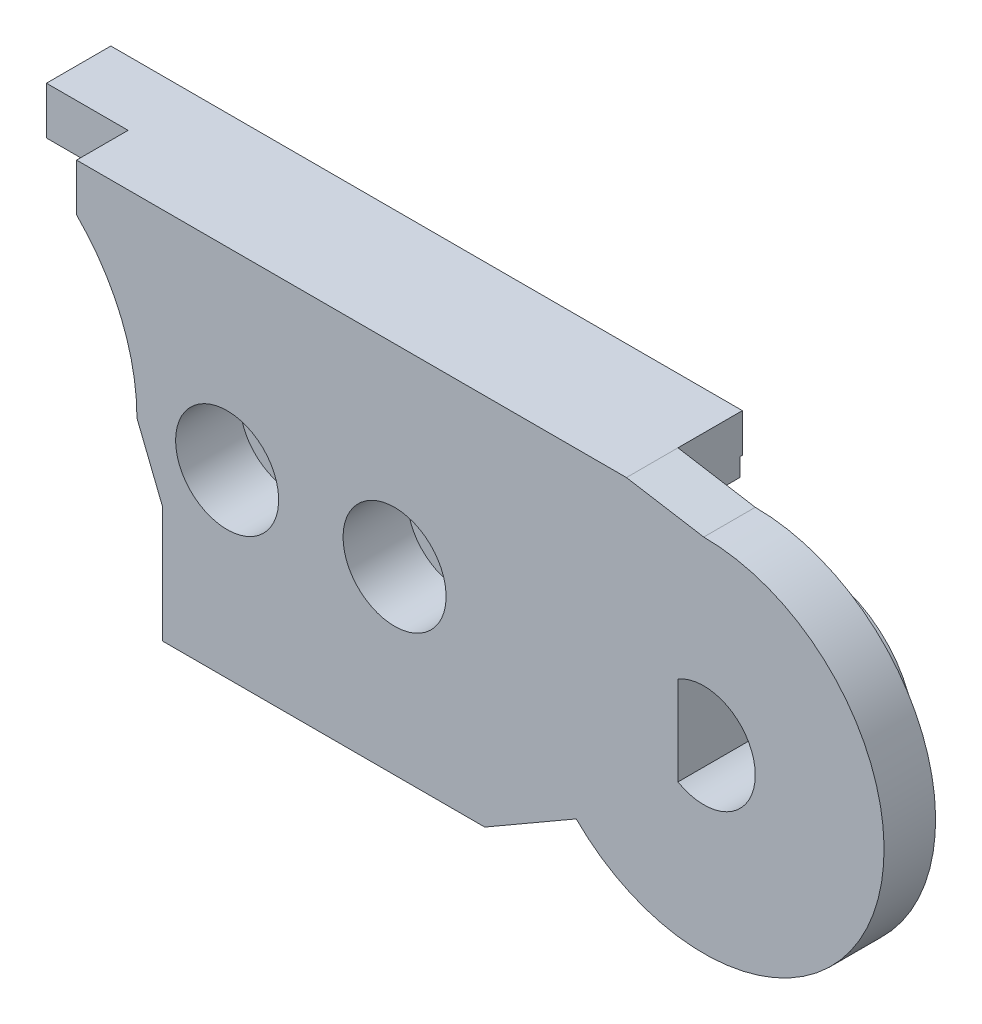
from build123d import *

# Parameters (mm, degrees)
BOSS_EXTRUDE1_DEPTH  = 2
BOSS_EXTRUDE6_DEPTH  = 2.5
CUT_EXTRUDE6_DEPTH   = 2.5
BOSS_EXTRUDE14_DEPTH = 2.3
SKETCH32_R           = 2.1
CUT_EXTRUDE7_DEPTH   = 2.3
SKETCH33_W           = 12.5
SKETCH33_H           = 1.343145751
BOSS_EXTRUDE15_DEPTH = 1.2
SKETCH35_W           = 5.479645997
SKETCH35_H           = 3.827993755
CUT_EXTRUDE8_DEPTH   = 2.4
SKETCH36_W           = 3.7
SKETCH36_H           = 1.827993755
CUT_EXTRUDE9_DEPTH   = 2.4
SKETCH37_R           = 3.9
BOSS_EXTRUDE16_DEPTH = 2.3
CUT_EXTRUDE10_DEPTH  = 5.3
SKETCH43_R           = 2.5
BOSS_EXTRUDE17_DEPTH = 1.2
SKETCH44_R           = 0.95
CUT_EXTRUDE11_DEPTH  = 9
SKETCH45_R           = 2
CUT_EXTRUDE12_DEPTH  = 2.5
SKETCH52_R           = 0.75
CUT_EXTRUDE13_DEPTH  = 10


with BuildPart() as part:
    # Sketch3 → Boss-Extrude1 (new body)
    with BuildSketch(Plane.XY):
        with BuildLine():
            Line((8, 0), (9, -2.5))
            Line((9, -2.5), (9, -7))
            Line((9, -7), (21.5, -7))
            Line((21.5, -7), (25.050252532, -4.949747468))
            ThreePointArc((25.050252532, -4.949747468), (36.467156728, -2.678784027), (30, 7))
            Line((30, 7), (27, 7.5))
            Line((27, 7.5), (5.656854249, 7.5))
            Line((5.656854249, 7.5), (5.656854249, 5.656854249))
            ThreePointArc((5.656854249, 5.656854249), (7.39103626, 3.061467459), (8, 0))
        make_face()
    extrude(amount=BOSS_EXTRUDE1_DEPTH)

    # Sketch22 → Boss-Extrude6 (add)
    with BuildSketch(Plane.XY.offset(2)):
        with BuildLine():
            Line((5.656854249, 5.656854249), (2.486790148, 5.656854249))
            Line((2.486790148, 5.656854249), (2.486790148, 7.5))
            Line((2.486790148, 7.5), (5.656854249, 7.5))
            Line((5.656854249, 7.5), (21.5, 7.5))
            Line((21.5, 7.5), (27, 7.5))
            Line((27, 7.5), (27, 2.172006245))
            Line((27, 2.172006245), (23.275126266, 2.172006245))
            Line((23.275126266, 2.172006245), (23.275126266, -5.974873734))
            Line((23.275126266, -5.974873734), (21.5, -7))
            Line((21.5, -7), (9, -7))
            Line((9, -7), (9, -2.5))
            Line((9, -2.5), (8, 0))
            ThreePointArc((8, 0), (7.39103626, 3.061467459), (5.656854249, 5.656854249))
        make_face()
    extrude(amount=BOSS_EXTRUDE6_DEPTH)

    # Sketch26 → Cut-Extrude6 (cut)
    with BuildSketch(Plane.XY.offset(2)):
        Polygon((18.098080448, 5.3), (2.530052458, 5.3), (2.530052458, 4), (18.098080448, 4), (27, 4), (27, 5.3), align=None)
    extrude(amount=CUT_EXTRUDE6_DEPTH, mode=Mode.SUBTRACT)


with BuildPart() as body_2:
    # Sketch31 → Boss-Extrude14 (new body)
    with BuildSketch(Plane.XY.offset(4.5)):
        with BuildLine():
            Line((2.432688066, 5.656854249), (0, 5.656854249))
            ThreePointArc((0, 5.656854249), (-5.656854249, 0), (0, -5.656854249))
            Line((0, -5.656854249), (9, -5.656854249))
            Line((9, -5.656854249), (9, -7))
            Line((9, -7), (21.5, -7))
            Line((21.5, -7), (23.275126266, -5.974873734))
            Line((23.275126266, -5.974873734), (23.275126266, 2.172006245))
            Line((23.275126266, 2.172006245), (27, 2.172006245))
            Line((27, 2.172006245), (27, 7.5))
            Line((27, 7.5), (2.486790148, 7.5))
            Line((2.486790148, 7.5), (2.432688066, 5.656854249))
        make_face()
    extrude(amount=BOSS_EXTRUDE14_DEPTH)

    # Sketch32 → Cut-Extrude7 (cut)
    with BuildSketch(Plane.XY.offset(6.8)):
        Circle(SKETCH32_R)
    extrude(amount=-CUT_EXTRUDE7_DEPTH, mode=Mode.SUBTRACT)

    # Sketch33 → Boss-Extrude15 (add)
    with BuildSketch(Plane.XY.offset(6.8)):
        with Locations((15.25, -6.328427125)):
            Rectangle(SKETCH33_W, SKETCH33_H)
        Polygon((2.486790148, 7.5), (21.5, 7.5), (21.5, 5.656854249), (2.432688066, 5.656854249), align=None)
    extrude(amount=BOSS_EXTRUDE15_DEPTH)


with BuildPart() as cut_extrude8_tool:
    # Sketch35 → Cut-Extrude8 (new body)
    with BuildSketch(Plane.XY.offset(6.8)):
        with Locations((24.260177002, 4.086003123)):
            Rectangle(SKETCH35_W, SKETCH35_H)
    extrude(amount=-CUT_EXTRUDE8_DEPTH)


with BuildPart() as part_1:
    add(part.part)

    # Cut-Extrude8: cut by cut_extrude8_tool
    add(cut_extrude8_tool.part, mode=Mode.SUBTRACT)

    # Sketch36 → Cut-Extrude9 (cut)
    with BuildSketch(Plane.XY.offset(4.4)):
        with Locations((25.15, 3.086003123)):
            Rectangle(SKETCH36_W, SKETCH36_H)
    extrude(amount=-CUT_EXTRUDE9_DEPTH, mode=Mode.SUBTRACT)

    # Sketch37 → Boss-Extrude16 (add)
    with BuildSketch(Plane.XY.offset(2)):
        with Locations((30, 0)):
            Circle(SKETCH37_R)
    extrude(amount=BOSS_EXTRUDE16_DEPTH)

    # Sketch39 → Cut-Extrude10 (cut, through all)
    with BuildSketch(Plane.XY.offset(4.3)):
        with BuildLine():
            Line((29, 1.732050808), (29, -1.732050808))
            ThreePointArc((29, -1.732050808), (32, 0), (29, 1.732050808))
        make_face()
    extrude(amount=-CUT_EXTRUDE10_DEPTH, mode=Mode.SUBTRACT)


with BuildPart() as body_2_1:
    add(body_2.part)

    # Cut-Extrude8: cut by cut_extrude8_tool
    add(cut_extrude8_tool.part, mode=Mode.SUBTRACT)

    # Sketch43 → Boss-Extrude17 (add)
    with BuildSketch(Plane.XY.offset(6.8)):
        with Locations((11.5, 0)):
            Circle(SKETCH43_R)
        with Locations((18, 0)):
            Circle(SKETCH43_R)
    extrude(amount=BOSS_EXTRUDE17_DEPTH)


with BuildPart() as cut_extrude11_tool:
    # Sketch44 → Cut-Extrude11 (new body, through all)
    with BuildSketch(Plane.XY.offset(8)):
        with Locations((11.5, 0)):
            Circle(SKETCH44_R)
        with Locations((18, 0)):
            Circle(SKETCH44_R)
    extrude(amount=-CUT_EXTRUDE11_DEPTH)


with BuildPart() as part_2:
    add(part_1.part)

    # Cut-Extrude11: cut by cut_extrude11_tool
    add(cut_extrude11_tool.part, mode=Mode.SUBTRACT)

    # Sketch45 → Cut-Extrude12 (cut)
    with BuildSketch(Plane(origin=(0, 0, 0), x_dir=(-1, 0, 0), z_dir=(0, 0, -1))):
        with Locations((-11.5, 0)):
            Circle(SKETCH45_R)
        with Locations((-18, 0)):
            Circle(SKETCH45_R)
    extrude(amount=-CUT_EXTRUDE12_DEPTH, mode=Mode.SUBTRACT)


with BuildPart() as body_2_2:
    add(body_2_1.part)

    # Cut-Extrude11: cut by cut_extrude11_tool
    add(cut_extrude11_tool.part, mode=Mode.SUBTRACT)

    # Sketch52 → Cut-Extrude13 (cut, along a direction that is not the sketch's normal)
    with BuildSketch(Plane.XZ.offset(-5.656854249)):
        with Locations((18.235476819, 8)):
            Circle(SKETCH52_R)
    extrude(amount=-CUT_EXTRUDE13_DEPTH, dir=(0.640410196, -0.76803306, 0), mode=Mode.SUBTRACT)


with BuildPart() as body_3:
    # Mirror1: mirrored copy
    add(body_2_2.part.mirror(Plane.XY.offset(8)))


with BuildPart() as body_4:
    # Mirror1 2: mirrored copy
    add(part_2.part.mirror(Plane.XY.offset(8)))


solid = body_4.part
